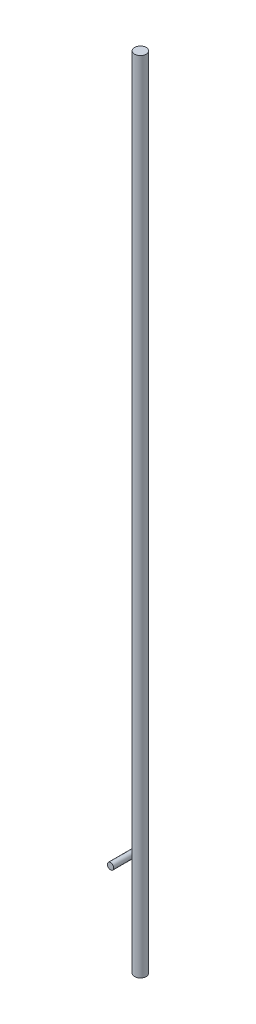
from build123d import *

# Parameters (mm, degrees)
SKETCH1_R           = 0.55
EXTRUDE1_DEPTH      = 66
EXTRUDE1_DEPTH_BACK = 9
SKETCH2_R           = 0.3
EXTRUDE2_DEPTH      = 2
EXTRUDE2_DEPTH_BACK = 0.5


with BuildPart() as part:
    # Sketch1 → Extrude1 (new body, two sides)
    with BuildSketch(Plane(origin=(0, 0, 0), x_dir=(1, 0, 0), z_dir=(0, 1, 0))) as extrude1_sk:
        Circle(SKETCH1_R)
    extrude(amount=EXTRUDE1_DEPTH)
    extrude(extrude1_sk.sketch, amount=-EXTRUDE1_DEPTH_BACK)

    # Sketch2 → Extrude2 (add, two sides)
    with BuildSketch(Plane.XY) as extrude2_sk:
        with Locations((-0.8, 0.3)):
            Circle(SKETCH2_R)
    extrude(amount=EXTRUDE2_DEPTH)
    extrude(extrude2_sk.sketch, amount=-EXTRUDE2_DEPTH_BACK)


solid = part.part
